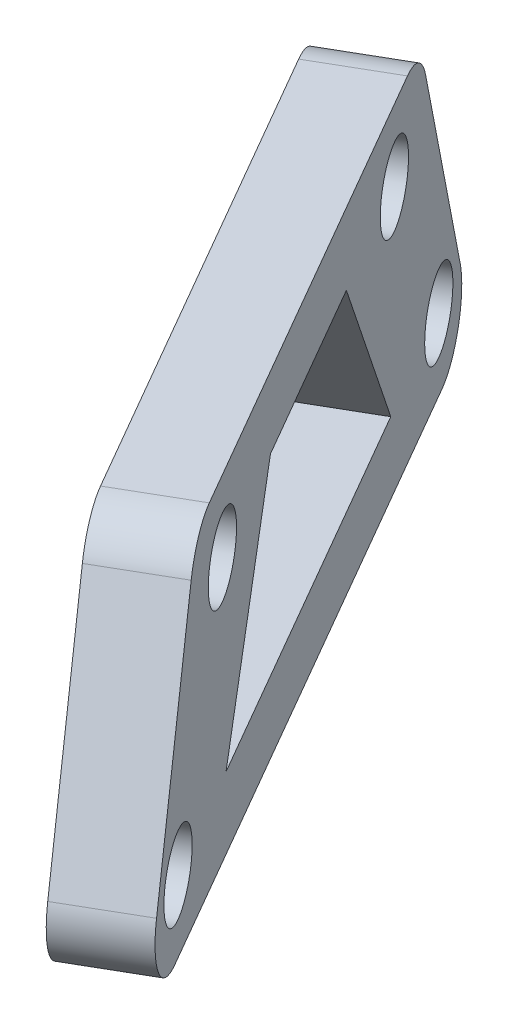
from build123d import *

# Parameters (mm, degrees)
SKETCH1_R           = 2.15
BOSS_EXTRUDE1_DEPTH = 4.45
FILLET1_R           = 3


with BuildPart() as part:
    # Sketch1 → Boss-Extrude1 (new body)
    with BuildSketch(Plane(origin=(-13.195504222, 0, 7.618427915), x_dir=(0.5, 0, 0.866025404), z_dir=(-0.866025404, 0, 0.5))):
        Polygon((-25.134165871, 118.055853922), (-17.360832538, 136.798849573), (16.885834129, 136.798849573), (24.659167462, 118.055853922), align=None)
        with Locations((-13.360832538, 132.798849573)):
            Circle(SKETCH1_R, mode=Mode.SUBTRACT)
        with Locations((12.885834129, 132.798849573)):
            Circle(SKETCH1_R, mode=Mode.SUBTRACT)
        with Locations((19.659167462, 122.055853922)):
            Circle(SKETCH1_R, mode=Mode.SUBTRACT)
        with Locations((-20.134165871, 122.055853922)):
            Circle(SKETCH1_R, mode=Mode.SUBTRACT)
        Polygon((-12.804739093, 122.055853922), (-6.03140576, 132.798849573), (5.556407351, 132.798849573), (12.329740684, 122.055853922), align=None, mode=Mode.SUBTRACT)
    extrude(amount=-BOSS_EXTRUDE1_DEPTH)

    # Fillet1
    fillet1_edges = [part.edges().sort_by_distance(p)[0] for p in [
        (-23.835680634, 118.055853922, -15.260898232),
        (-19.949013967, 136.798849573, -8.528994094),
        (-2.825680634, 136.798849573, 21.129489235),
        (1.060986033, 118.055853922, 27.861393373),
    ]]
    fillet(fillet1_edges, radius=FILLET1_R)


solid = part.part
